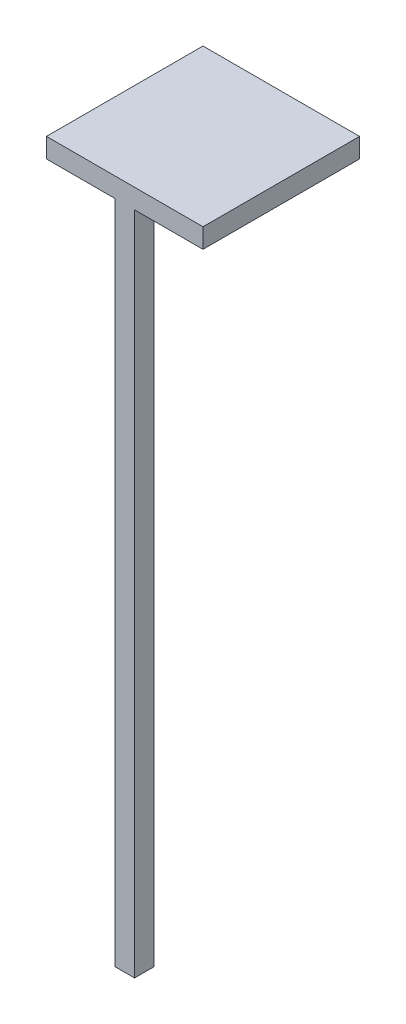
from build123d import *

# Parameters (mm, degrees)
ESQUISSE1_W      = 10
ESQUISSE1_H      = 10
EXTRUSION1_DEPTH = 340
ESQUISSE2_W      = 80
ESQUISSE2_H      = 80
EXTRUSION2_DEPTH = 10


with BuildPart() as part:
    # Esquisse1 → Extrusion1 (new body)
    with BuildSketch(Plane(origin=(0, 0, 0), x_dir=(1, 0, 0), z_dir=(0, 1, 0))):
        with Locations((5, 5)):
            Rectangle(ESQUISSE1_W, ESQUISSE1_H)
    extrude(amount=EXTRUSION1_DEPTH)

    # Esquisse2 → Extrusion2 (add)
    with BuildSketch(Plane(origin=(0, 340, 0), x_dir=(1, 0, 0), z_dir=(0, 1, 0))):
        with Locations((5, 40)):
            Rectangle(ESQUISSE2_W, ESQUISSE2_H)
    extrude(amount=EXTRUSION2_DEPTH)


solid = part.part
